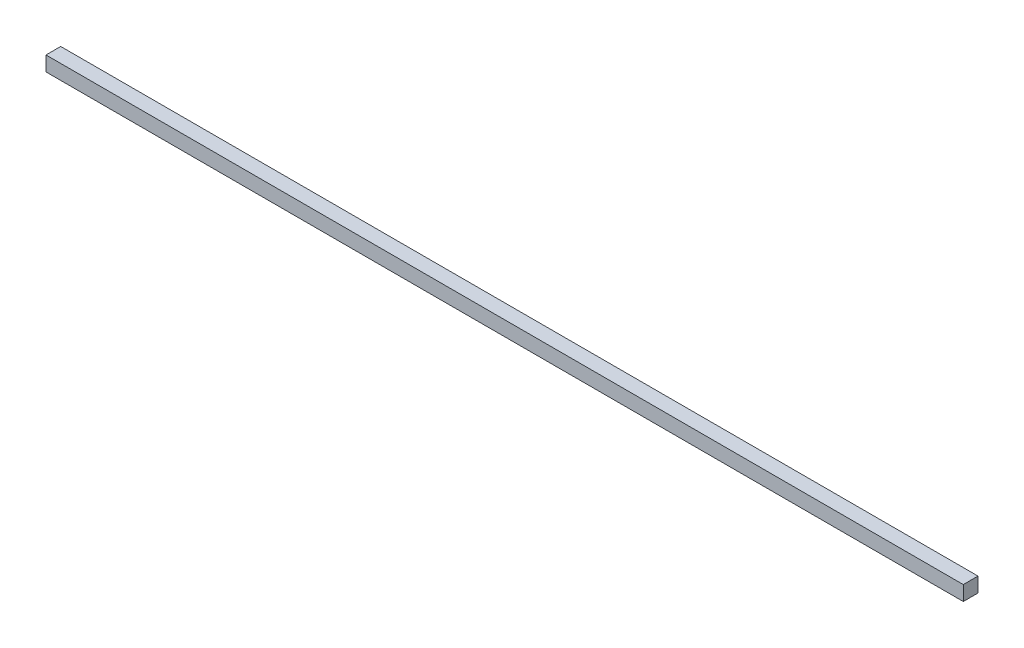
from build123d import *

# Parameters (mm, degrees)
SKETCH1_W           = 187
SKETCH1_H           = 3
BOSS_EXTRUDE1_DEPTH = 3


with BuildPart() as part:
    # Sketch1 → Boss-Extrude1 (new body)
    with BuildSketch(Plane(origin=(0, 0, 0), x_dir=(1, 0, 0), z_dir=(0, 1, 0))):
        with Locations((93.5, 1.5)):
            Rectangle(SKETCH1_W, SKETCH1_H)
    extrude(amount=BOSS_EXTRUDE1_DEPTH)


solid = part.part
